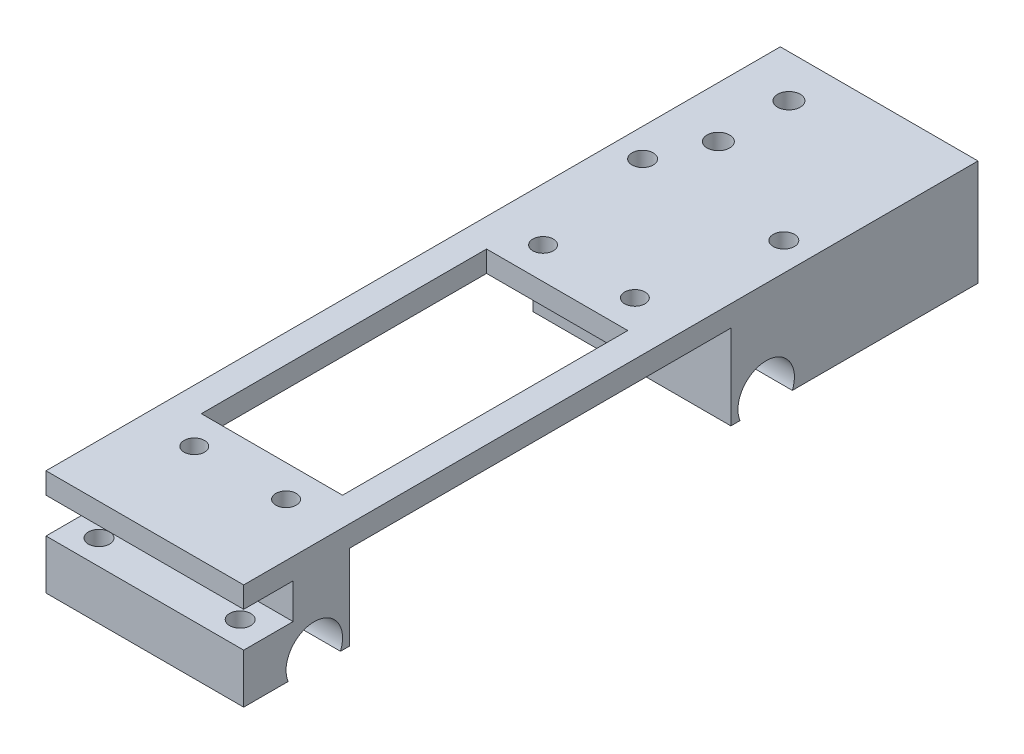
from build123d import *

# Parameters (mm, degrees)
SKETCH1_W                                           = 28
SKETCH1_H                                           = 84
BOSS_EXTRUDE2_DEPTH                                 = 15
SKETCH7_W                                           = 54
SKETCH7_H                                           = 12
CUT_EXTRUDE2_DEPTH                                  = 1
CUT_EXTRUDE2_DEPTH_BACK                             = 29
SKETCH6_W                                           = 20
SKETCH6_H                                           = 40.4
CUT_EXTRUDE1_DEPTH                                  = 16
SKETCH8_W                                           = 28
SKETCH8_H                                           = 5
CUT_EXTRUDE3_DEPTH                                  = 7
SKETCH9_R                                           = 1.45
CUT_EXTRUDE4_DEPTH                                  = 6
SKETCH11_R                                          = 4
CUT_EXTRUDE5_DEPTH                                  = 1
CUT_EXTRUDE5_DEPTH_BACK                             = 29
SKETCH12_R                                          = 1.5
CUT_EXTRUDE6_DEPTH                                  = 8
SKETCH13_R                                          = 1.5
CUT_EXTRUDE7_DEPTH                                  = 16
BOSS_EXTRUDE3_DEPTH                                 = 20
CUT_EXTRUDE10_DEPTH                                 = 25
CBORE_FOR_M3_HEX_SOCKET_HEAD_CAP_SCREW1_D           = 3.2
CBORE_FOR_M3_HEX_SOCKET_HEAD_CAP_SCREW1_CBORE_D     = 6.5
CBORE_FOR_M3_HEX_SOCKET_HEAD_CAP_SCREW1_CBORE_DEPTH = 3.4


with BuildPart() as part:
    # Sketch1 → Boss-Extrude2 (new body)
    with BuildSketch(Plane(origin=(0, 0, 0), x_dir=(1, 0, 0), z_dir=(0, 1, 0))):
        with Locations((14, 42)):
            Rectangle(SKETCH1_W, SKETCH1_H)
    extrude(amount=BOSS_EXTRUDE2_DEPTH)

    # Sketch7 → Cut-Extrude2 (cut, two sides)
    with BuildSketch(Plane(origin=(28, 0, 0), x_dir=(0, 0, -1), z_dir=(1, 0, 0))) as cut_extrude2_sk:
        with Locations((42, 6)):
            Rectangle(SKETCH7_W, SKETCH7_H)
    extrude(amount=CUT_EXTRUDE2_DEPTH, mode=Mode.SUBTRACT)
    extrude(cut_extrude2_sk.sketch, amount=-CUT_EXTRUDE2_DEPTH_BACK, mode=Mode.SUBTRACT)

    # Sketch6 → Cut-Extrude1 (cut, through all)
    with BuildSketch(Plane(origin=(0, 15, 0), x_dir=(1, 0, 0), z_dir=(0, 1, 0))):
        with Locations((14, 38.2)):
            Rectangle(SKETCH6_W, SKETCH6_H)
    extrude(amount=-CUT_EXTRUDE1_DEPTH, mode=Mode.SUBTRACT)

    # Sketch8 → Cut-Extrude3 (cut)
    with BuildSketch(Plane.XY):
        with Locations((14, 9.5)):
            Rectangle(SKETCH8_W, SKETCH8_H)
    extrude(amount=-CUT_EXTRUDE3_DEPTH, mode=Mode.SUBTRACT)

    # Sketch9 → Cut-Extrude4 (cut)
    with BuildSketch(Plane(origin=(0, 15, 0), x_dir=(1, 0, 0), z_dir=(0, 1, 0))):
        with Locations((7.5, 13.5)):
            Circle(SKETCH9_R)
        with Locations((20.5, 13.5)):
            Circle(SKETCH9_R)
        with Locations((7.5, 62.9)):
            Circle(SKETCH9_R)
        with Locations((20.5, 62.9)):
            Circle(SKETCH9_R)
    extrude(amount=-CUT_EXTRUDE4_DEPTH, mode=Mode.SUBTRACT)

    # Sketch11 → Cut-Extrude5 (cut, two sides)
    with BuildSketch(Plane.ZY) as cut_extrude5_sk:
        with Locations((-10, 1.5)):
            Circle(SKETCH11_R)
        with Locations((-74, 1.5)):
            Circle(SKETCH11_R)
    extrude(amount=CUT_EXTRUDE5_DEPTH, mode=Mode.SUBTRACT)
    extrude(cut_extrude5_sk.sketch, amount=-CUT_EXTRUDE5_DEPTH_BACK, mode=Mode.SUBTRACT)

    # Sketch12 → Cut-Extrude6 (cut)
    with BuildSketch(Plane.XZ):
        with Locations((4, -3.5)):
            Circle(SKETCH12_R)
        with Locations((24, -3.5)):
            Circle(SKETCH12_R)
    extrude(amount=-CUT_EXTRUDE6_DEPTH, mode=Mode.SUBTRACT)

    # Sketch13 → Cut-Extrude7 (cut, through all)
    with BuildSketch(Plane.XZ):
        with Locations((4, -80.5)):
            Circle(SKETCH13_R)
        with Locations((24, -80.5)):
            Circle(SKETCH13_R)
    extrude(amount=-CUT_EXTRUDE7_DEPTH, mode=Mode.SUBTRACT)

    # Sketch15 → Boss-Extrude3 (add)
    with BuildSketch(Plane(origin=(0, 0, -84), x_dir=(-1, 0, 0), z_dir=(0, 0, -1))):
        with BuildLine():
            Line((-28, 15), (0, 15))
            Line((0, 15), (0, 8.75))
            Line((0, 8.75), (-10.200328962, 8.75))
            ThreePointArc((-10.200328962, 8.75), (-15.594420664, 11.168490527), (-17.506165925, 5.574694698))
            Line((-17.506165925, 5.574694698), (-10.466462197, 5.625403884))
            ThreePointArc((-10.466462197, 5.625403884), (-10.271009725, 6.05271581), (-10.127016654, 6.5))
            Line((-10.127016654, 6.5), (0, 6.5))
            Line((0, 6.5), (0, 0))
            Line((0, 0), (-28, 0))
            Line((-28, 0), (-28, 15))
        make_face()
    extrude(amount=BOSS_EXTRUDE3_DEPTH)

    # Sketch17 → Cut-Extrude10 (cut)
    with BuildSketch(Plane(origin=(0, 0, -104), x_dir=(-1, 0, 0), z_dir=(0, 0, -1))):
        with BuildLine():
            Line((0, 8.75), (-10.200328962, 8.75))
            ThreePointArc((-10.200328962, 8.75), (-15.594420664, 11.168490527), (-17.506165925, 5.574694698))
            Line((-17.506165925, 5.574694698), (-10.466462197, 5.625403884))
            ThreePointArc((-10.466462197, 5.625403884), (-10.271009725, 6.05271581), (-10.127016654, 6.5))
            Line((-10.127016654, 6.5), (0, 6.5))
            Line((0, 6.5), (0, 8.75))
        make_face()
    extrude(amount=-CUT_EXTRUDE10_DEPTH, mode=Mode.SUBTRACT)

    # CBORE for M3 Hex Socket Head Cap Screw1 (through all)
    with Locations(Plane(origin=(7.226315369, 0, -88), x_dir=(0, 0, -1), z_dir=(0, -1, 0))):
        with Locations((0, 0), (10, 0)):
            CounterBoreHole(CBORE_FOR_M3_HEX_SOCKET_HEAD_CAP_SCREW1_D / 2, CBORE_FOR_M3_HEX_SOCKET_HEAD_CAP_SCREW1_CBORE_D / 2, CBORE_FOR_M3_HEX_SOCKET_HEAD_CAP_SCREW1_CBORE_DEPTH)


solid = part.part
